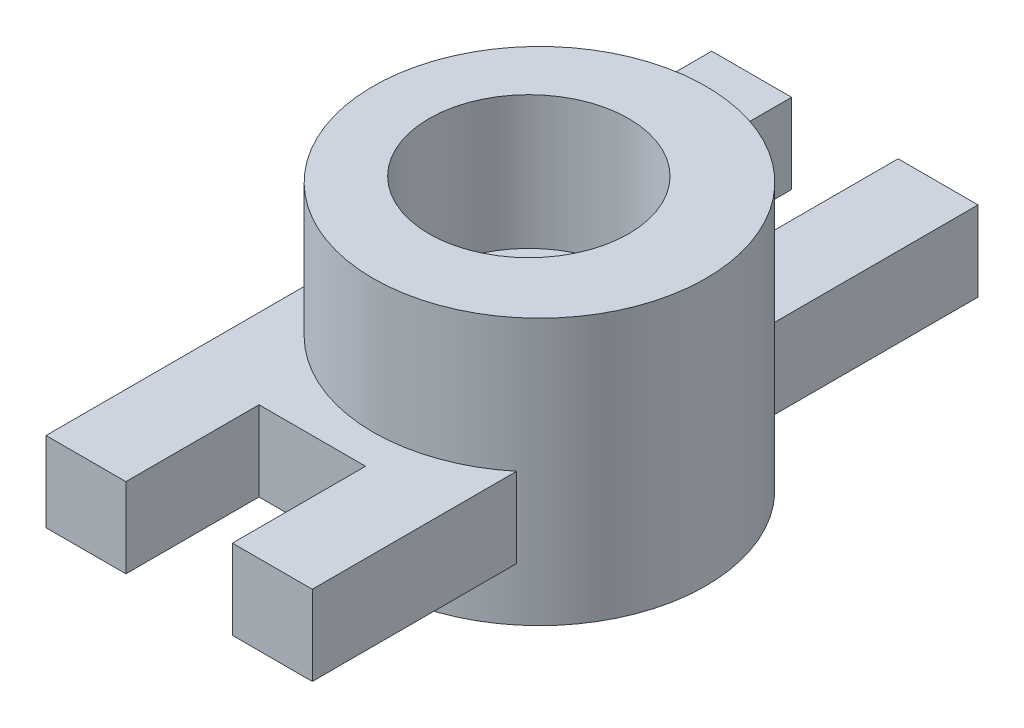
from build123d import *

# Parameters (mm, degrees)
SKETCH1_W           = 100
SKETCH1_H           = 12
BOSS_EXTRUDE1_DEPTH = 40
SKETCH3_R           = 25
SKETCH3_R_2         = 15
BOSS_EXTRUDE3_DEPTH = 20
SKETCH8_W           = 16
SKETCH8_H           = 12
CUT_EXTRUDE3_DEPTH  = 20
SKETCH9_W           = 16
SKETCH9_H           = 12
CUT_EXTRUDE4_DEPTH  = 20


with BuildPart() as part:
    # Sketch1 → Boss-Extrude1 (new body)
    with BuildSketch(Plane(origin=(0, 0, 0), x_dir=(0, 0, -1), z_dir=(1, 0, 0))):
        with Locations((15.090909091, -0.181818182)):
            Rectangle(SKETCH1_W, SKETCH1_H)
    extrude(amount=-BOSS_EXTRUDE1_DEPTH)

    # Sketch3 → Boss-Extrude3 (add, symmetric)
    with BuildSketch(Plane(origin=(0, 5.818181818, 0), x_dir=(1, 0, 0), z_dir=(0, 1, 0))):
        with Locations((-15.870623847, 15.090909091)):
            Circle(SKETCH3_R)
        with Locations((-17.470623847, 15.090909091)):
            Circle(SKETCH3_R_2, mode=Mode.SUBTRACT)
    extrude(amount=BOSS_EXTRUDE3_DEPTH, both=True)

    # Sketch8 → Cut-Extrude3 (cut)
    with BuildSketch(Plane.XY.offset(34.909090909)):
        with Locations((-20, -0.181818182)):
            Rectangle(SKETCH8_W, SKETCH8_H)
    extrude(amount=-CUT_EXTRUDE3_DEPTH, mode=Mode.SUBTRACT)

    # Sketch9 → Cut-Extrude4 (cut)
    with BuildSketch(Plane(origin=(0, 0, -65.090909091), x_dir=(-1, 0, 0), z_dir=(0, 0, -1))):
        with Locations((20, -0.181818182)):
            Rectangle(SKETCH9_W, SKETCH9_H)
    extrude(amount=-CUT_EXTRUDE4_DEPTH, mode=Mode.SUBTRACT)


solid = part.part
